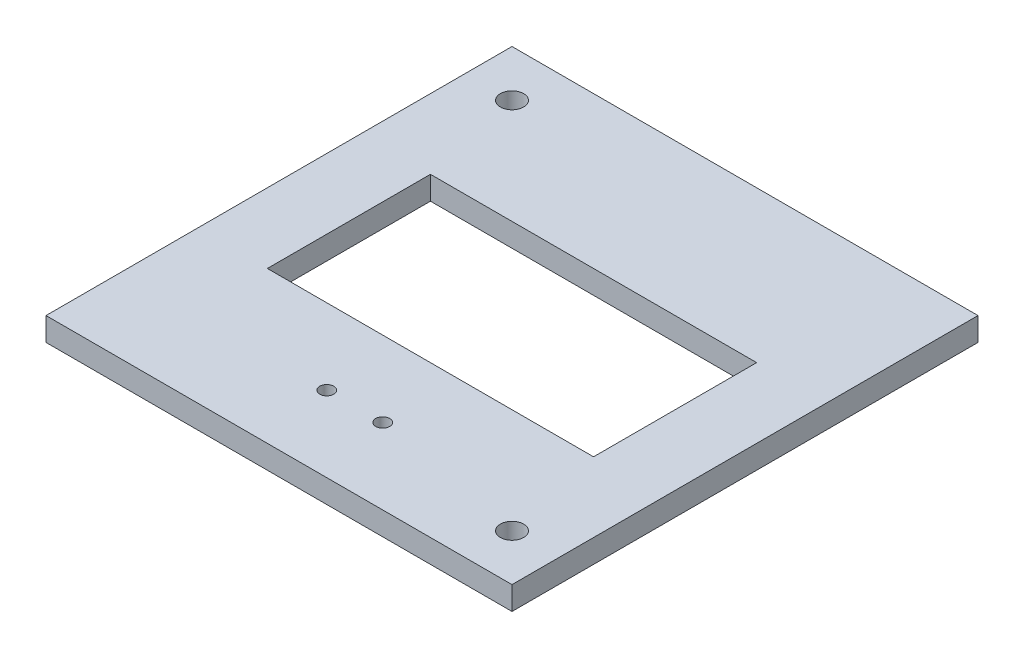
from build123d import *

# Parameters (mm, degrees)
SKETCH1_W           = 100
SKETCH1_H           = 100
SKETCH1_R           = 1.5
SKETCH1_R_2         = 2.5
SKETCH1_W_2         = 70
SKETCH1_H_2         = 35
BOSS_EXTRUDE1_DEPTH = 5


with BuildPart() as part:
    # Sketch1 → Boss-Extrude1 (new body)
    with BuildSketch(Plane(origin=(0, 0, 0), x_dir=(1, 0, 0), z_dir=(0, 1, 0))):
        with Locations((-50, 50)):
            Rectangle(SKETCH1_W, SKETCH1_H)
        with Locations((-56, 16.25)):
            Circle(SKETCH1_R, mode=Mode.SUBTRACT)
        with Locations((-44, 16.25)):
            Circle(SKETCH1_R, mode=Mode.SUBTRACT)
        with Locations((-90, 90)):
            Circle(SKETCH1_R_2, mode=Mode.SUBTRACT)
        with Locations((-10, 10)):
            Circle(SKETCH1_R_2, mode=Mode.SUBTRACT)
        with Locations((-50, 50)):
            Rectangle(SKETCH1_W_2, SKETCH1_H_2, mode=Mode.SUBTRACT)
    extrude(amount=BOSS_EXTRUDE1_DEPTH)


solid = part.part
